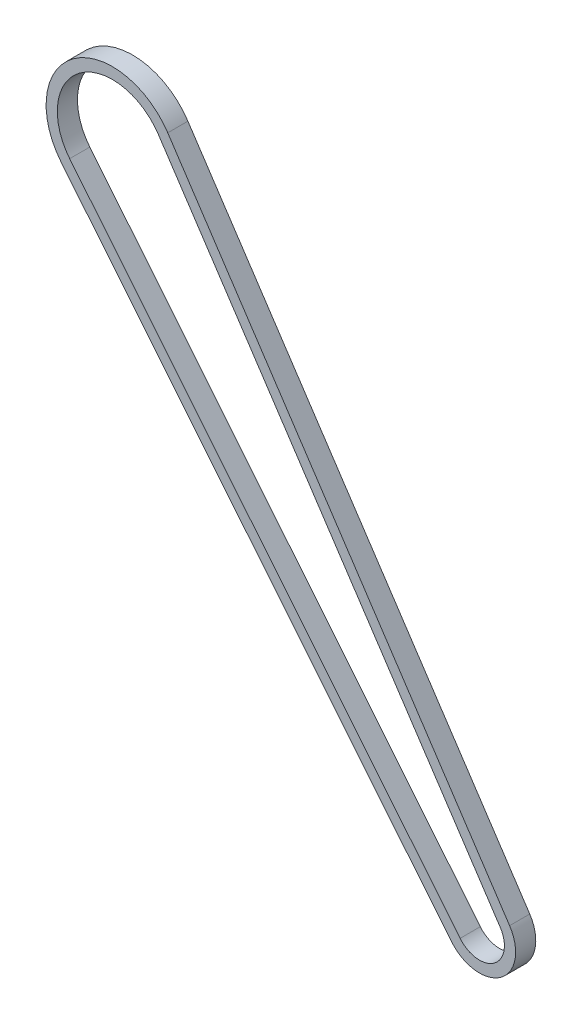
from build123d import *

# Parameters (mm, degrees)
EXTRUDE_THIN1_DEPTH = 9


with BuildPart() as part:
    # Sketch2 → Extrude-Thin1 (new body)
    with BuildSketch(Plane.XY):
        with BuildLine():
            Line((151.378668263, -233.043363361), (-22.981780911, -18.694340619))
            ThreePointArc((-22.981780911, -18.694340619), (-17.551849204, 23.865733061), (24.692942596, 16.367626918))
            Line((24.692942596, 16.367626918), (177.352340412, -213.941248389))
            ThreePointArc((177.352340412, -213.941248389), (173.461800416, -235.860790332), (151.378668263, -233.043363361))
        make_face()
        with BuildLine():
            Line((155.257449851, -229.888200388), (-19.102999323, -15.539177645))
            ThreePointArc((-19.102999323, -15.539177645), (-14.589511785, 19.837761236), (20.525357348, 13.60515824))
            Line((20.525357348, 13.60515824), (173.184755163, -216.703717068))
            ThreePointArc((173.184755163, -216.703717068), (170.499462998, -231.832818508), (155.257449851, -229.888200388))
        make_face(mode=Mode.SUBTRACT)
    extrude(amount=-EXTRUDE_THIN1_DEPTH)


solid = part.part
